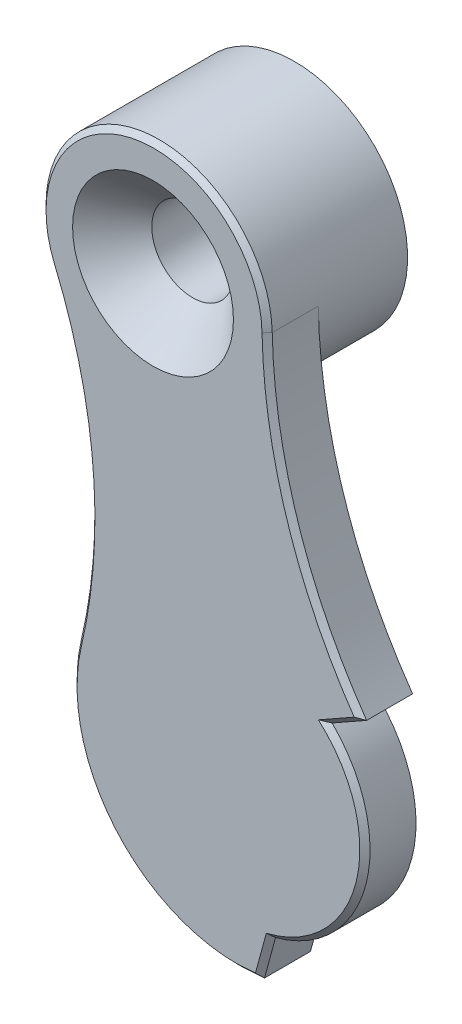
from build123d import *

# Parameters (mm, degrees)
EXTRUDE_1_DEPTH              = 2
SKETCH_2_R                   = 4.43
EXTRUDE_2_DEPTH              = 3.5
HOLE_WIZARD_M3_1_D           = 3.2
HOLE_WIZARD_M3_1_CSINK_D     = 6.3
HOLE_WIZARD_M3_1_CSINK_ANGLE = 90
SKETCH_8_R                   = 3
EXTRUDE_3_DEPTH              = 0.9
SKETCH_10_R                  = 1.52
CUT_EXTRUDE_1_DEPTH          = 2
CHAMFER_1_SIZE               = 0.2


with BuildPart() as part:
    # 草图1 → 凸台-拉伸1 (new body)
    with BuildSketch(Plane(origin=(0, 0, 12.16), x_dir=(-1, 0, 0), z_dir=(0, 0, -1))):
        with BuildLine():
            Line((10.90083304, -4.828267309), (11.334013857, -6.416349492))
            Line((11.334013857, -6.416349492), (12.2, -6.475))
            ThreePointArc((12.2, -6.475), (17.274650028, -4.0216355), (18.503750642, 1.479308233))
            ThreePointArc((18.503750642, 1.479308233), (18.045416815, 7.727850312), (19.542869864, 13.811597708))
            ThreePointArc((19.542869864, 13.811597708), (16.382825591, 19.863959761), (11.031173747, 15.624055427))
            ThreePointArc((11.031173747, 15.624055427), (10.022718521, 9.69776671), (7.334091643, 4.321042298))
            Line((7.334091643, 4.321042298), (8.685883448, 3.556822298))
            ThreePointArc((8.685883448, 3.556822298), (7.365813774, -1.276966534), (10.90083304, -4.828267309))
        make_face()
    extrude(amount=-EXTRUDE_1_DEPTH)

    # 草图2 → 凸台-拉伸2 (add)
    with BuildSketch(Plane(origin=(0, 0, 12.16), x_dir=(-1, 0, 0), z_dir=(0, 0, -1))):
        with Locations((15.460198425, 15.531101684)):
            Circle(SKETCH_2_R)
    extrude(amount=EXTRUDE_2_DEPTH)

    # M3 平头机械螺钉的锥形沉头孔1 (through all)
    with Locations(Plane.XY.offset(14.16)):
        with Locations((-15.5, 15.5)):
            CounterSinkHole(HOLE_WIZARD_M3_1_D / 2, HOLE_WIZARD_M3_1_CSINK_D / 2, counter_sink_angle=HOLE_WIZARD_M3_1_CSINK_ANGLE)

    # 草图8 → 凸台-拉伸3 (add)
    with BuildSketch(Plane(origin=(0, 0, 12.16), x_dir=(-1, 0, 0), z_dir=(0, 0, -1))):
        with Locations((12.24, 0)):
            Circle(SKETCH_8_R)
    extrude(amount=EXTRUDE_3_DEPTH)

    # 草图10 → 切除-拉伸1 (cut)
    with BuildSketch(Plane.XY.offset(11.26)):
        with Locations((-12.2, 0)):
            Circle(SKETCH_10_R)
    extrude(amount=CUT_EXTRUDE_1_DEPTH, mode=Mode.SUBTRACT)

    # 倒角1
    chamfer_1_edges = [part.edges().sort_by_distance(p)[0] for p in [
        (-16.382825591, 19.863959761, 14.16),
        (-10.022718521, 9.69776671, 14.16),
        (-8.009987545, 3.938932298, 14.16),
        (-7.365813774, -1.276966534, 14.16),
        (-11.117423449, -5.622308401, 14.16),
        (-11.767006928, -6.445674746, 14.16),
        (-17.274650028, -4.0216355, 14.16),
        (-18.045416815, 7.727850312, 14.16),
    ]]
    chamfer(chamfer_1_edges, length=CHAMFER_1_SIZE)


solid = part.part
